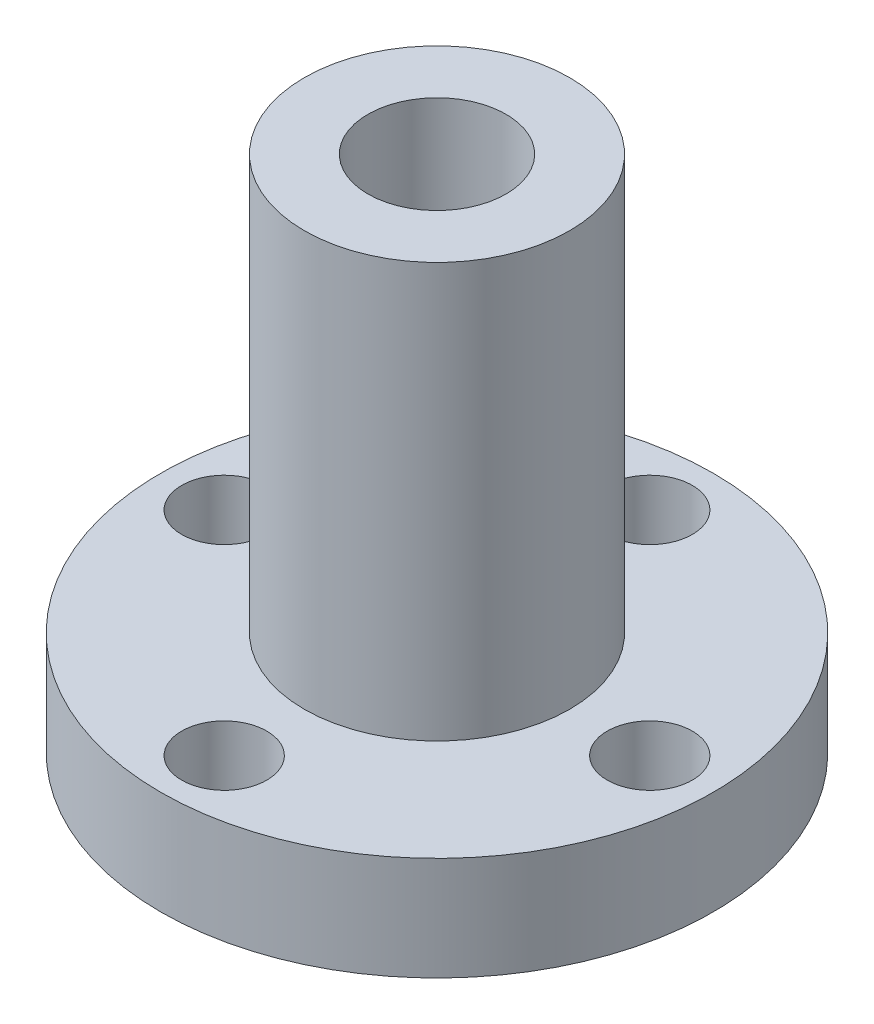
from build123d import *

# Parameters (mm, degrees)
SKETCH1_R           = 12.7
SKETCH1_R_2         = 1.9558
SKETCH1_R_3         = 3.175
BOSS_EXTRUDE1_DEPTH = 4.7625
BOSS_EXTRUDE2_START = 19.05
SKETCH1_3_R         = 6.096
SKETCH1_3_R_2       = 3.175
BOSS_EXTRUDE2_DEPTH = 19.05


with BuildPart() as part:
    # Sketch1 → Boss-Extrude1 (new body)
    with BuildSketch(Plane(origin=(0, 0, 0), x_dir=(1, 0, 0), z_dir=(0, 1, 0))):
        Circle(SKETCH1_R)
        with Locations((-9.779, 0)):
            Circle(SKETCH1_R_2, mode=Mode.SUBTRACT)
        with Locations((0, -9.779)):
            Circle(SKETCH1_R_2, mode=Mode.SUBTRACT)
        with Locations((9.779, 0)):
            Circle(SKETCH1_R_2, mode=Mode.SUBTRACT)
        with Locations((0, 9.779)):
            Circle(SKETCH1_R_2, mode=Mode.SUBTRACT)
        Circle(SKETCH1_R_3, mode=Mode.SUBTRACT)
    extrude(amount=-BOSS_EXTRUDE1_DEPTH)

    # Sketch1_3 → Boss-Extrude2 (add)
    with BuildSketch(Plane(origin=(0, 0, 0), x_dir=(1, 0, 0), z_dir=(0, 1, 0)).offset(BOSS_EXTRUDE2_START)):
        Circle(SKETCH1_3_R)
        Circle(SKETCH1_3_R_2, mode=Mode.SUBTRACT)
    extrude(amount=-BOSS_EXTRUDE2_DEPTH)


solid = part.part
